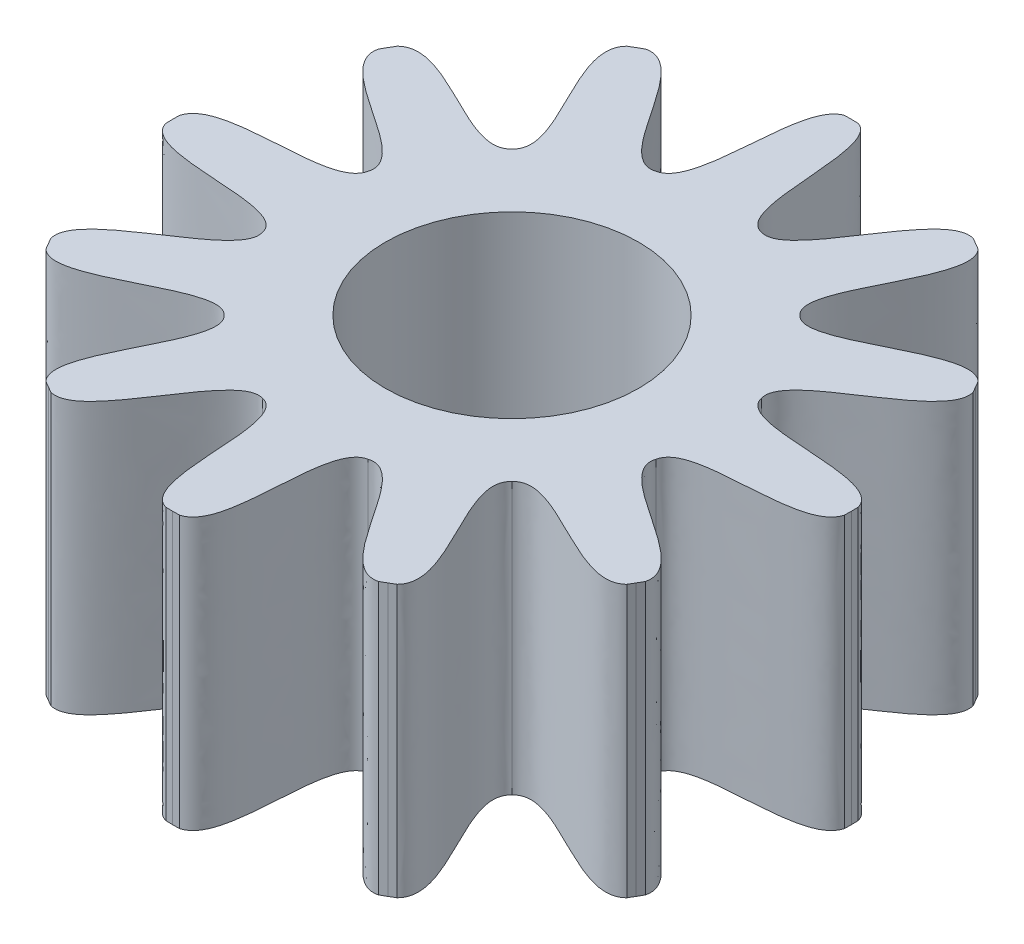
from build123d import *

# Parameters (mm, degrees)
BOSS_EXTRUDE1_12_TEETH_DEPTH = 0.6
CUT_EXTRUDE1_REACH           = 2.6
SKETCH2_R                    = 0.28


with BuildPart() as part:
    # Sketch1 → Boss-Extrude1 (12 teeth) (new body)
    with BuildSketch(Plane(origin=(0, 0, 0), x_dir=(1, 0, 0), z_dir=(0, 1, 0))):
        with BuildLine():
            Line((0, 0.75), (0.01499925, 0.74985))
            add(Edge.make_bspline(
                [(0.01499925, 0.74985), (0.089770208, 0.726526589), (0.037536283, 0.45058181), (0.11646857, 0.434666622)],
                knots=[0, 0, 0, 0, 1, 1, 1, 1], degree=3))
            add(Edge.make_bspline(
                [(0.361935268, 0.656888774), (0.27667218, 0.679442999), (0.19278353, 0.408983436), (0.11646857, 0.434666622)],
                knots=[0, 0, 0, 0, 1, 1, 1, 1], degree=3))
            Line((0.361935268, 0.656888774), (0.375, 0.649519053))
            Line((0.375, 0.649519053), (0.387914732, 0.641889524))
            add(Edge.make_bspline(
                [(0.387914732, 0.641889524), (0.450078807, 0.579326636), (0.25779828, 0.371447153), (0.318198052, 0.318198052)],
                knots=[0, 0, 0, 0, 1, 1, 1, 1], degree=3))
            add(Edge.make_bspline(
                [(0.641889524, 0.387914732), (0.579326636, 0.450078807), (0.371447153, 0.25779828), (0.318198052, 0.318198052)],
                knots=[0, 0, 0, 0, 1, 1, 1, 1], degree=3))
            Line((0.641889524, 0.387914732), (0.649519053, 0.375))
            Line((0.649519053, 0.375), (0.656888774, 0.361935268))
            add(Edge.make_bspline(
                [(0.656888774, 0.361935268), (0.679442999, 0.27667218), (0.408983436, 0.19278353), (0.434666622, 0.11646857)],
                knots=[0, 0, 0, 0, 1, 1, 1, 1], degree=3))
            add(Edge.make_bspline(
                [(0.74985, 0.01499925), (0.726750987, 0.100116363), (0.45058181, 0.037536283), (0.434666622, 0.11646857)],
                knots=[0, 0, 0, 0, 1, 1, 1, 1], degree=3))
            Line((0.74985, 0.01499925), (0.75, 0))
            Line((0.75, 0), (0.74985, -0.01499925))
            add(Edge.make_bspline(
                [(0.74985, -0.01499925), (0.726750987, -0.100116363), (0.45058181, -0.037536283), (0.434666622, -0.11646857)],
                knots=[0, 0, 0, 0, 1, 1, 1, 1], degree=3))
            add(Edge.make_bspline(
                [(0.656888774, -0.361935268), (0.679442999, -0.27667218), (0.408983436, -0.19278353), (0.434666622, -0.11646857)],
                knots=[0, 0, 0, 0, 1, 1, 1, 1], degree=3))
            Line((0.656888774, -0.361935268), (0.649519053, -0.375))
            Line((0.649519053, -0.375), (0.641889524, -0.387914732))
            add(Edge.make_bspline(
                [(0.641889524, -0.387914732), (0.579326636, -0.450078807), (0.371447153, -0.25779828), (0.318198052, -0.318198052)],
                knots=[0, 0, 0, 0, 1, 1, 1, 1], degree=3))
            add(Edge.make_bspline(
                [(0.387914732, -0.641889524), (0.450078807, -0.579326636), (0.25779828, -0.371447153), (0.318198052, -0.318198052)],
                knots=[0, 0, 0, 0, 1, 1, 1, 1], degree=3))
            Line((0.387914732, -0.641889524), (0.375, -0.649519053))
            Line((0.375, -0.649519053), (0.361935268, -0.656888774))
            add(Edge.make_bspline(
                [(0.361935268, -0.656888774), (0.27667218, -0.679442999), (0.19278353, -0.408983436), (0.11646857, -0.434666622)],
                knots=[0, 0, 0, 0, 1, 1, 1, 1], degree=3))
            add(Edge.make_bspline(
                [(0.01499925, -0.74985), (0.100116363, -0.726750987), (0.037536283, -0.45058181), (0.11646857, -0.434666622)],
                knots=[0, 0, 0, 0, 1, 1, 1, 1], degree=3))
            Line((0.01499925, -0.74985), (0, -0.75))
            Line((0, -0.75), (-0.01499925, -0.74985))
            add(Edge.make_bspline(
                [(-0.01499925, -0.74985), (-0.100116363, -0.726750987), (-0.037536283, -0.45058181), (-0.11646857, -0.434666622)],
                knots=[0, 0, 0, 0, 1, 1, 1, 1], degree=3))
            add(Edge.make_bspline(
                [(-0.361935268, -0.656888774), (-0.27667218, -0.679442999), (-0.19278353, -0.408983436), (-0.11646857, -0.434666622)],
                knots=[0, 0, 0, 0, 1, 1, 1, 1], degree=3))
            Line((-0.361935268, -0.656888774), (-0.375, -0.649519053))
            Line((-0.375, -0.649519053), (-0.387914732, -0.641889524))
            add(Edge.make_bspline(
                [(-0.387914732, -0.641889524), (-0.450078807, -0.579326636), (-0.25779828, -0.371447153), (-0.318198052, -0.318198052)],
                knots=[0, 0, 0, 0, 1, 1, 1, 1], degree=3))
            add(Edge.make_bspline(
                [(-0.641889524, -0.387914732), (-0.579326636, -0.450078807), (-0.371447153, -0.25779828), (-0.318198052, -0.318198052)],
                knots=[0, 0, 0, 0, 1, 1, 1, 1], degree=3))
            Line((-0.641889524, -0.387914732), (-0.649519053, -0.375))
            Line((-0.649519053, -0.375), (-0.656888774, -0.361935268))
            add(Edge.make_bspline(
                [(-0.656888774, -0.361935268), (-0.679442999, -0.27667218), (-0.408983436, -0.19278353), (-0.434666622, -0.11646857)],
                knots=[0, 0, 0, 0, 1, 1, 1, 1], degree=3))
            add(Edge.make_bspline(
                [(-0.74985, -0.01499925), (-0.726750987, -0.100116363), (-0.45058181, -0.037536283), (-0.434666622, -0.11646857)],
                knots=[0, 0, 0, 0, 1, 1, 1, 1], degree=3))
            Line((-0.74985, -0.01499925), (-0.75, 0))
            Line((-0.75, 0), (-0.74985, 0.01499925))
            add(Edge.make_bspline(
                [(-0.74985, 0.01499925), (-0.726750987, 0.100116363), (-0.45058181, 0.037536283), (-0.434666622, 0.11646857)],
                knots=[0, 0, 0, 0, 1, 1, 1, 1], degree=3))
            add(Edge.make_bspline(
                [(-0.656888774, 0.361935268), (-0.679442999, 0.27667218), (-0.408983436, 0.19278353), (-0.434666622, 0.11646857)],
                knots=[0, 0, 0, 0, 1, 1, 1, 1], degree=3))
            Line((-0.656888774, 0.361935268), (-0.649519053, 0.375))
            Line((-0.649519053, 0.375), (-0.641889524, 0.387914732))
            add(Edge.make_bspline(
                [(-0.641889524, 0.387914732), (-0.579326636, 0.450078807), (-0.371447153, 0.25779828), (-0.318198052, 0.318198052)],
                knots=[0, 0, 0, 0, 1, 1, 1, 1], degree=3))
            add(Edge.make_bspline(
                [(-0.387914732, 0.641889524), (-0.450078807, 0.579326636), (-0.25779828, 0.371447153), (-0.318198052, 0.318198052)],
                knots=[0, 0, 0, 0, 1, 1, 1, 1], degree=3))
            Line((-0.387914732, 0.641889524), (-0.375, 0.649519053))
            Line((-0.375, 0.649519053), (-0.361935268, 0.656888774))
            add(Edge.make_bspline(
                [(-0.361935268, 0.656888774), (-0.27667218, 0.679442999), (-0.19278353, 0.408983436), (-0.11646857, 0.434666622)],
                knots=[0, 0, 0, 0, 1, 1, 1, 1], degree=3))
            add(Edge.make_bspline(
                [(-0.01499925, 0.74985), (-0.089770208, 0.726526589), (-0.037536283, 0.45058181), (-0.11646857, 0.434666622)],
                knots=[0, 0, 0, 0, 1, 1, 1, 1], degree=3))
            Line((-0.01499925, 0.74985), (0, 0.75))
        make_face()
    extrude(amount=BOSS_EXTRUDE1_12_TEETH_DEPTH)

    # Sketch2 → Cut-Extrude1 (cut, up to next)
    with BuildSketch(Plane(origin=(0, 0, 0), x_dir=(1, 0, 0), z_dir=(0, 1, 0)), mode=Mode.PRIVATE) as cut_extrude1_sk1:
        Circle(SKETCH2_R)
    cut_extrude1_tool1 = extrude(cut_extrude1_sk1.sketch, amount=CUT_EXTRUDE1_REACH, mode=Mode.PRIVATE) & part.part
    add(cut_extrude1_tool1.solids().sort_by_distance((0, 0, 0))[0], mode=Mode.SUBTRACT)


solid = part.part
